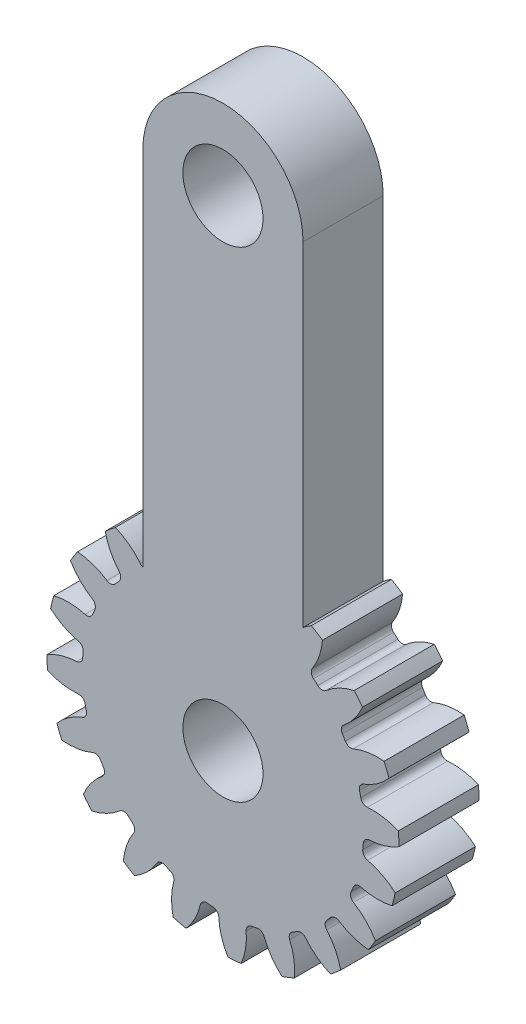
from build123d import *

# Parameters (mm, degrees)
SKETCH3_R           = 27.94
GEARBODY_DEPTH      = 12.7
TOOTHCUT_DEPTH      = 13.7
CIRPATTERN1_COUNT   = 20
BOREDIA_R           = 6.35
BORE_DEPTH          = 12700
SKETCH4_R           = 6.35
BOSS_EXTRUDE1_DEPTH = 12.7


with BuildPart() as part:
    # Sketch3 → gearBody (new body)
    with BuildSketch(Plane.XY):
        Circle(SKETCH3_R)
    extrude(amount=GEARBODY_DEPTH)

    # Sketch2 → toothCut (cut, through all)
    with BuildSketch(Plane.XY):
        with BuildLine():
            ThreePointArc((22.161994813, -2.487872048), (22.207832173, -2.038556256), (22.244560977, -1.58840435))
            ThreePointArc((22.244560977, -1.58840435), (22.544698475, -0.941259068), (23.198766614, -0.656523398))
            ThreePointArc((23.198766614, -0.656523398), (27.638401864, 0.614170289), (31.045266607, 3.731588487))
            ThreePointArc((31.045266607, 3.731588487), (31.137815759, -2.858279396), (29.847095445, -9.321170787))
            ThreePointArc((29.847095445, -9.321170787), (27.064706273, -5.635613286), (22.930600611, -3.577897568))
            ThreePointArc((22.930600611, -3.577897568), (22.339300546, -3.17884398), (22.161994813, -2.487872048))
        make_face()
    toothcut = extrude(amount=TOOTHCUT_DEPTH, mode=Mode.SUBTRACT)

    # CirPattern1: toothCut ×20 about axis
    cirpattern1_axis = Axis((0, 0, 0), (0, 0, 1))
    for i in range(1, CIRPATTERN1_COUNT):
        add(toothcut.rotate(cirpattern1_axis, i * 360 / CIRPATTERN1_COUNT), mode=Mode.SUBTRACT)

    # boreDia → bore (cut, symmetric)
    with BuildSketch(Plane.XY):
        Circle(BOREDIA_R)
    extrude(amount=BORE_DEPTH, both=True, mode=Mode.SUBTRACT)

    # Sketch4 → Boss-Extrude1 (add)
    with BuildSketch(Plane.XY):
        with BuildLine():
            Line((12.7, 18.331762639), (12.7, 76.2))
            ThreePointArc((12.7, 76.2), (0, 88.9), (-12.7, 76.2))
            Line((-12.7, 76.2), (-12.7, 18.331762639))
            ThreePointArc((-12.7, 18.331762639), (0, 22.3012), (12.7, 18.331762639))
        make_face()
        with Locations((0, 76.2)):
            Circle(SKETCH4_R, mode=Mode.SUBTRACT)
    extrude(amount=BOSS_EXTRUDE1_DEPTH)


solid = part.part
